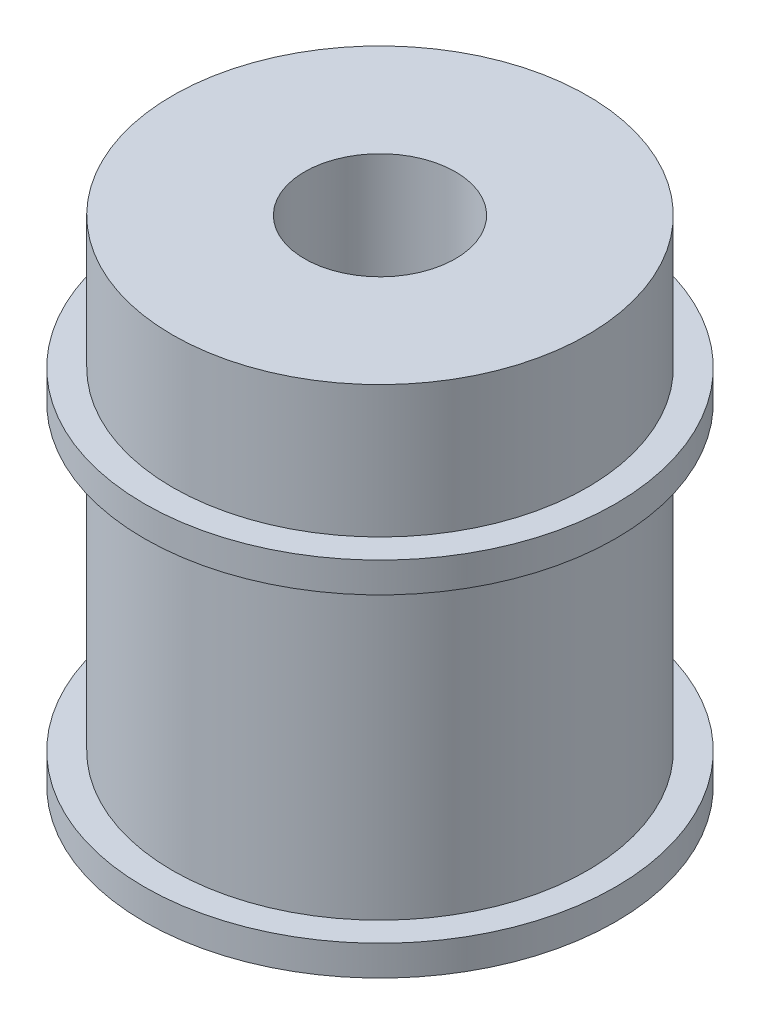
from build123d import *

# Parameters (mm, degrees)
SKETCH1_R           = 12.5
BOSS_EXTRUDE1_DEPTH = 1.6
SKETCH2_R           = 11
BOSS_EXTRUDE2_DEPTH = 16
SKETCH3_R           = 12.5
BOSS_EXTRUDE3_DEPTH = 1.6
SKETCH4_R           = 11
BOSS_EXTRUDE4_DEPTH = 7
SKETCH5_R           = 4
CUT_EXTRUDE1_DEPTH  = 27.2


with BuildPart() as part:
    # Sketch1 → Boss-Extrude1 (new body)
    with BuildSketch(Plane(origin=(0, 0, 0), x_dir=(1, 0, 0), z_dir=(0, 1, 0))):
        Circle(SKETCH1_R)
    extrude(amount=BOSS_EXTRUDE1_DEPTH)

    # Sketch2 → Boss-Extrude2 (add)
    with BuildSketch(Plane(origin=(0, 1.6, 0), x_dir=(1, 0, 0), z_dir=(0, 1, 0))):
        Circle(SKETCH2_R)
    extrude(amount=BOSS_EXTRUDE2_DEPTH)

    # Sketch3 → Boss-Extrude3 (add)
    with BuildSketch(Plane(origin=(0, 17.6, 0), x_dir=(1, 0, 0), z_dir=(0, 1, 0))):
        Circle(SKETCH3_R)
    extrude(amount=BOSS_EXTRUDE3_DEPTH)

    # Sketch4 → Boss-Extrude4 (add)
    with BuildSketch(Plane(origin=(0, 19.2, 0), x_dir=(1, 0, 0), z_dir=(0, 1, 0))):
        Circle(SKETCH4_R)
    extrude(amount=BOSS_EXTRUDE4_DEPTH)

    # Sketch5 → Cut-Extrude1 (cut, through all)
    with BuildSketch(Plane.XZ):
        Circle(SKETCH5_R)
    extrude(amount=-CUT_EXTRUDE1_DEPTH, mode=Mode.SUBTRACT)


solid = part.part
